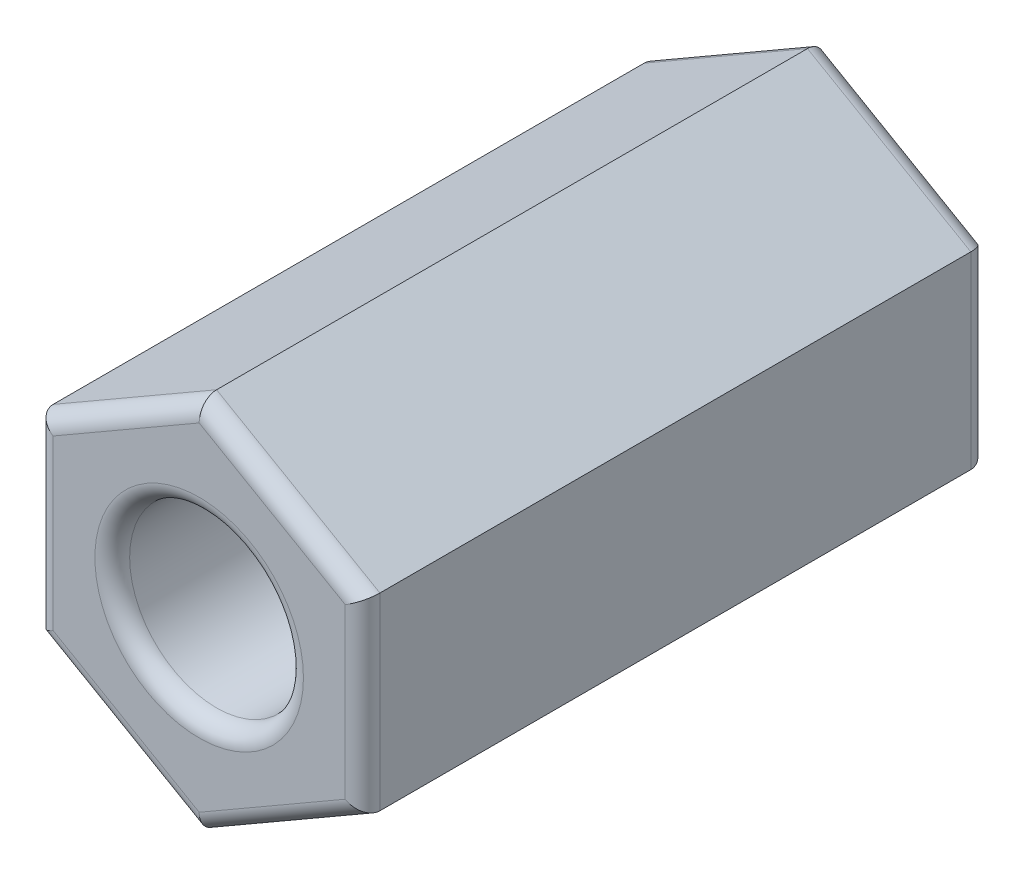
from build123d import *

# Parameters (mm, degrees)
CROQUIS1_R              = 1.25
SALIENTE_EXTRUIR1_DEPTH = 9
REDONDEO1_R             = 0.25
REDONDEO2_R             = 0.25


with BuildPart() as part:
    # Croquis1 → Saliente-Extruir1 (new body)
    with BuildSketch(Plane.XY):
        Polygon((2.35, 1.356773133), (0, 2.713546265), (-2.35, 1.356773133), (-2.35, -1.356773133), (0, -2.713546265), (2.35, -1.356773133), align=None)
        Circle(CROQUIS1_R, mode=Mode.SUBTRACT)
    extrude(amount=SALIENTE_EXTRUIR1_DEPTH)

    # Redondeo1
    redondeo1_edges = [part.edges().sort_by_distance(p)[0] for p in [
        (-1.175, 2.035159699, 9),
        (-2.35, 0, 9),
        (-1.175, -2.035159699, 9),
        (1.175, -2.035159699, 9),
        (2.35, 0, 9),
        (1.175, -2.035159699, 0),
        (-1.175, -2.035159699, 0),
        (-2.35, 0, 0),
        (1.175, 2.035159699, 9),
        (-1.175, 2.035159699, 0),
        (1.175, 2.035159699, 0),
        (2.35, 0, 0),
    ]]
    fillet(redondeo1_edges, radius=REDONDEO1_R)

    # Redondeo2
    redondeo2_edges = [part.edges().sort_by_distance(p)[0] for p in [
        (-1.25, 0, 0),
        (-1.25, 0, 9),
    ]]
    fillet(redondeo2_edges, radius=REDONDEO2_R)


solid = part.part
